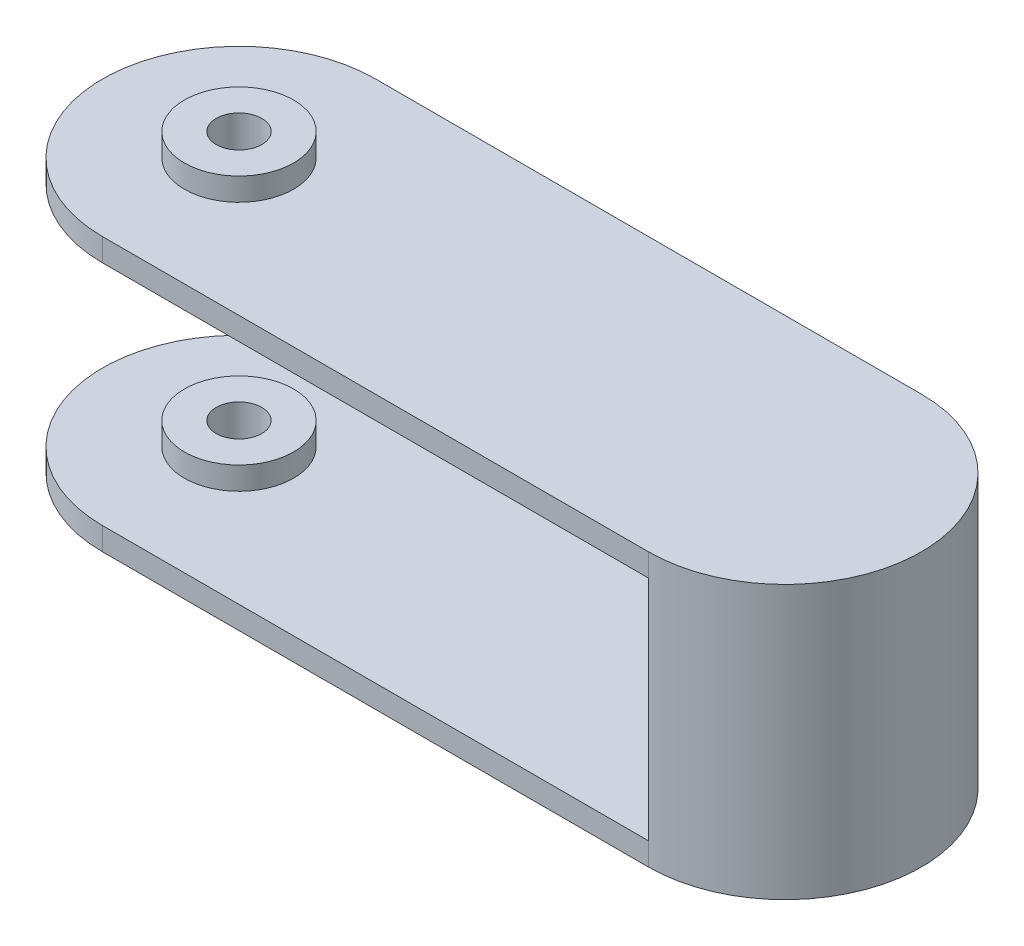
from build123d import *

# Parameters (mm, degrees)
BOSS_EXTRUDE1_DEPTH     = 30
SKETCH4_R               = 2.5
CUT_EXTRUDE1_DEPTH      = 1
CUT_EXTRUDE1_DEPTH_BACK = 46
SKETCH6_W               = 75
SKETCH6_H               = 25
CUT_EXTRUDE3_DEPTH      = 31
SKETCH7_R               = 6
SKETCH7_R_2             = 2.5
BOSS_EXTRUDE2_DEPTH     = 2.5
SKETCH8_R               = 6
SKETCH8_R_2             = 2.5
BOSS_EXTRUDE3_DEPTH     = 5


with BuildPart() as part:
    # Sketch1 → Boss-Extrude1 (new body)
    with BuildSketch(Plane(origin=(0, 0, 0), x_dir=(1, 0, 0), z_dir=(0, 1, 0))):
        with BuildLine():
            Line((-30, 15), (30, 15))
            ThreePointArc((30, 15), (45, 0), (30, -15))
            Line((30, -15), (-30, -15))
            ThreePointArc((-30, -15), (-45, 0), (-30, 15))
        make_face()
    extrude(amount=BOSS_EXTRUDE1_DEPTH)

    # Sketch4 → Cut-Extrude1 (cut, two sides)
    with BuildSketch(Plane(origin=(0, 30, 0), x_dir=(1, 0, 0), z_dir=(0, 1, 0))) as cut_extrude1_sk:
        with Locations((-30, 0)):
            Circle(SKETCH4_R)
    extrude(amount=CUT_EXTRUDE1_DEPTH, mode=Mode.SUBTRACT)
    extrude(cut_extrude1_sk.sketch, amount=-CUT_EXTRUDE1_DEPTH_BACK, mode=Mode.SUBTRACT)

    # Sketch6 → Cut-Extrude3 (cut, through all)
    with BuildSketch(Plane.XY.offset(15)):
        with Locations((-7.5, 15)):
            Rectangle(SKETCH6_W, SKETCH6_H)
    extrude(amount=-CUT_EXTRUDE3_DEPTH, mode=Mode.SUBTRACT)

    # Sketch7 → Boss-Extrude2 (add)
    with BuildSketch(Plane(origin=(0, 30, 0), x_dir=(1, 0, 0), z_dir=(0, 1, 0))):
        with Locations((-30, 0)):
            Circle(SKETCH7_R)
        with Locations((-30, 0)):
            Circle(SKETCH7_R_2, mode=Mode.SUBTRACT)
    extrude(amount=BOSS_EXTRUDE2_DEPTH)

    # Sketch8 → Boss-Extrude3 (add)
    with BuildSketch(Plane.XZ):
        with Locations((-30, 0)):
            Circle(SKETCH8_R)
        with Locations((-30, 0)):
            Circle(SKETCH8_R_2, mode=Mode.SUBTRACT)
    extrude(amount=-BOSS_EXTRUDE3_DEPTH)


solid = part.part
